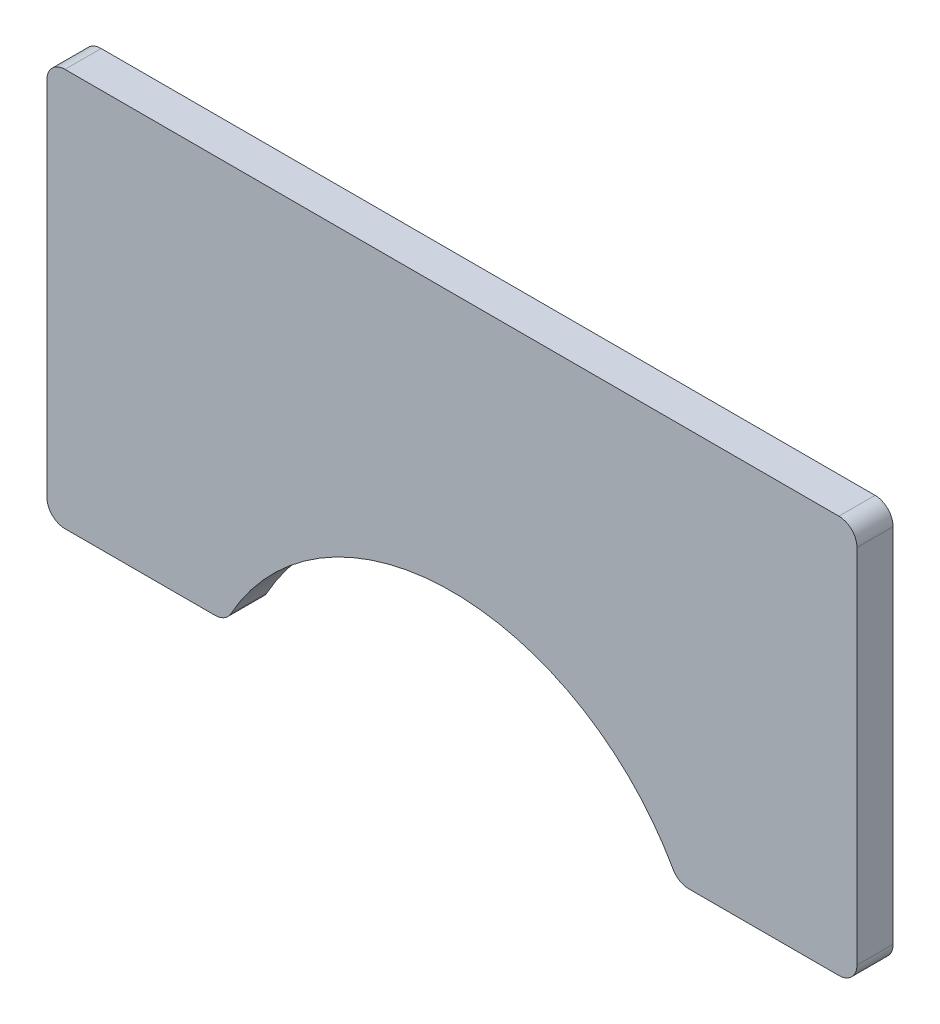
from build123d import *

# Parameters (mm, degrees)
SKETCH1_W           = 56.896
SKETCH1_H           = 27.94
BOSS_EXTRUDE1_DEPTH = 2.54
CUT_EXTRUDE1_DEPTH  = 3.54
FILLET1_R           = 1.27


with BuildPart() as part:
    # Sketch1 → Boss-Extrude1 (new body)
    with BuildSketch(Plane.XY):
        Rectangle(SKETCH1_W, SKETCH1_H)
    extrude(amount=BOSS_EXTRUDE1_DEPTH)

    # Sketch2 → Cut-Extrude1 (cut, through all)
    with BuildSketch(Plane.XY.offset(2.54)):
        with BuildLine():
            Line((-15.875, -13.97), (15.875, -13.97))
            ThreePointArc((15.875, -13.97), (0, -4.197045335), (-15.875, -13.97))
        make_face()
    extrude(amount=-CUT_EXTRUDE1_DEPTH, mode=Mode.SUBTRACT)

    # Fillet1
    fillet1_edges = [part.edges().sort_by_distance(p)[0] for p in [
        (-15.875, -13.97, 1.27),
        (15.875, -13.97, 1.27),
        (28.448, -13.97, 1.27),
        (-28.448, -13.97, 1.27),
        (-28.448, 13.97, 1.27),
        (28.448, 13.97, 1.27),
    ]]
    fillet(fillet1_edges, radius=FILLET1_R)


solid = part.part
